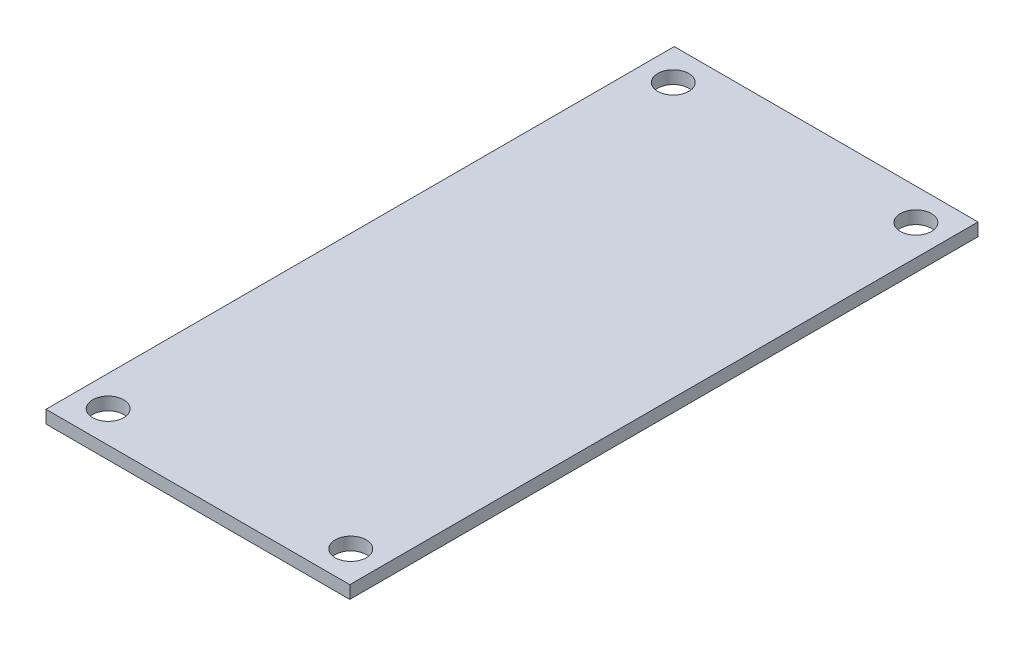
from build123d import *

# Parameters (mm, degrees)
SKETCH1_W           = 30.8
SKETCH1_H           = 63.7
SKETCH1_R           = 1.575
BOSS_EXTRUDE1_DEPTH = 1.3


with BuildPart() as part:
    # Sketch1 → Boss-Extrude1 (new body)
    with BuildSketch(Plane(origin=(0, 0, 0), x_dir=(1, 0, 0), z_dir=(0, 1, 0))):
        Rectangle(SKETCH1_W, SKETCH1_H)
        with Locations((12.3, 28.65)):
            Circle(SKETCH1_R, mode=Mode.SUBTRACT)
        with Locations((-12.3, 28.65)):
            Circle(SKETCH1_R, mode=Mode.SUBTRACT)
        with Locations((-12.3, -28.65)):
            Circle(SKETCH1_R, mode=Mode.SUBTRACT)
        with Locations((12.3, -28.65)):
            Circle(SKETCH1_R, mode=Mode.SUBTRACT)
    extrude(amount=BOSS_EXTRUDE1_DEPTH)


solid = part.part
